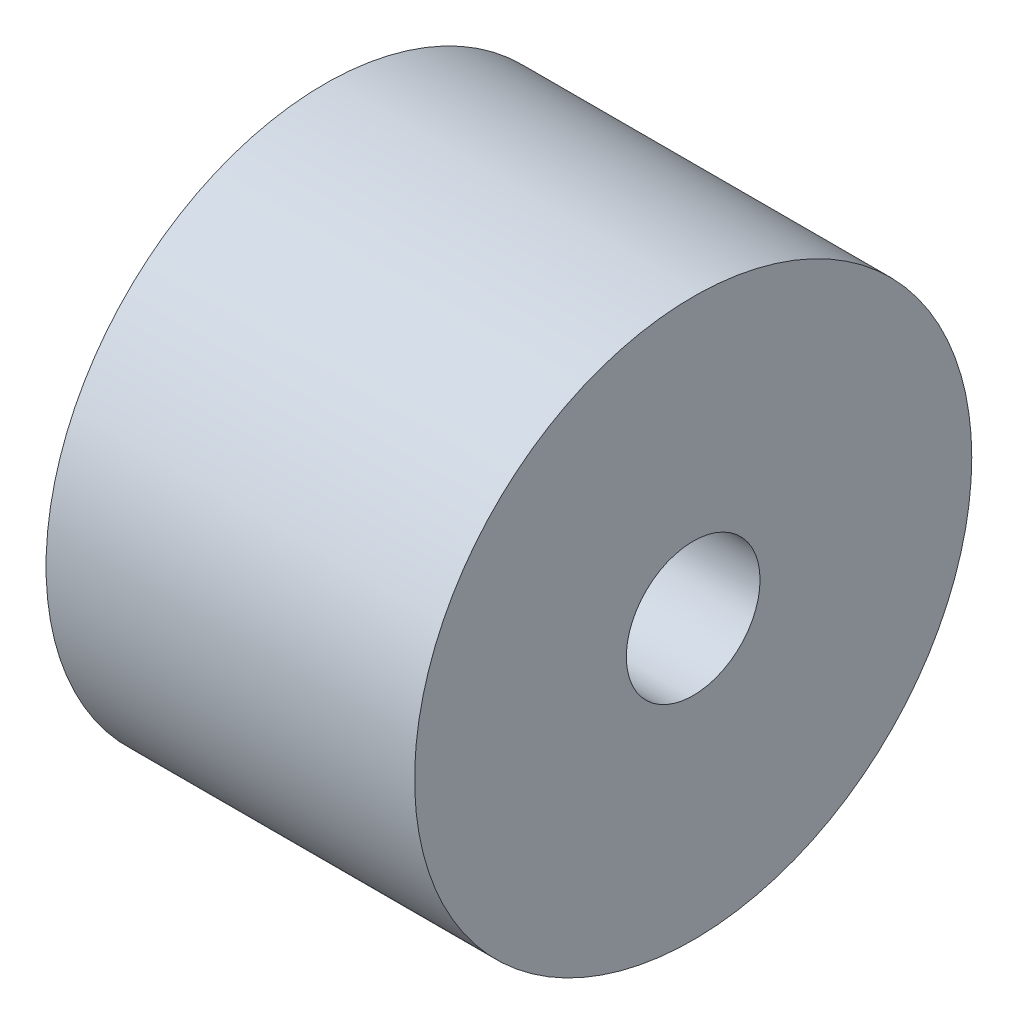
from build123d import *

# Parameters (mm, degrees)
SKETCH1_W = 10.5
SKETCH1_H = 6.0325


with BuildPart() as part:
    # Sketch1 → Revolve1 (revolve)
    with BuildSketch(Plane.XY):
        with Locations((5.25, 4.92125)):
            Rectangle(SKETCH1_W, SKETCH1_H)
    revolve(axis=Axis((0, 0, 0), (-1, 0, 0)))


solid = part.part
